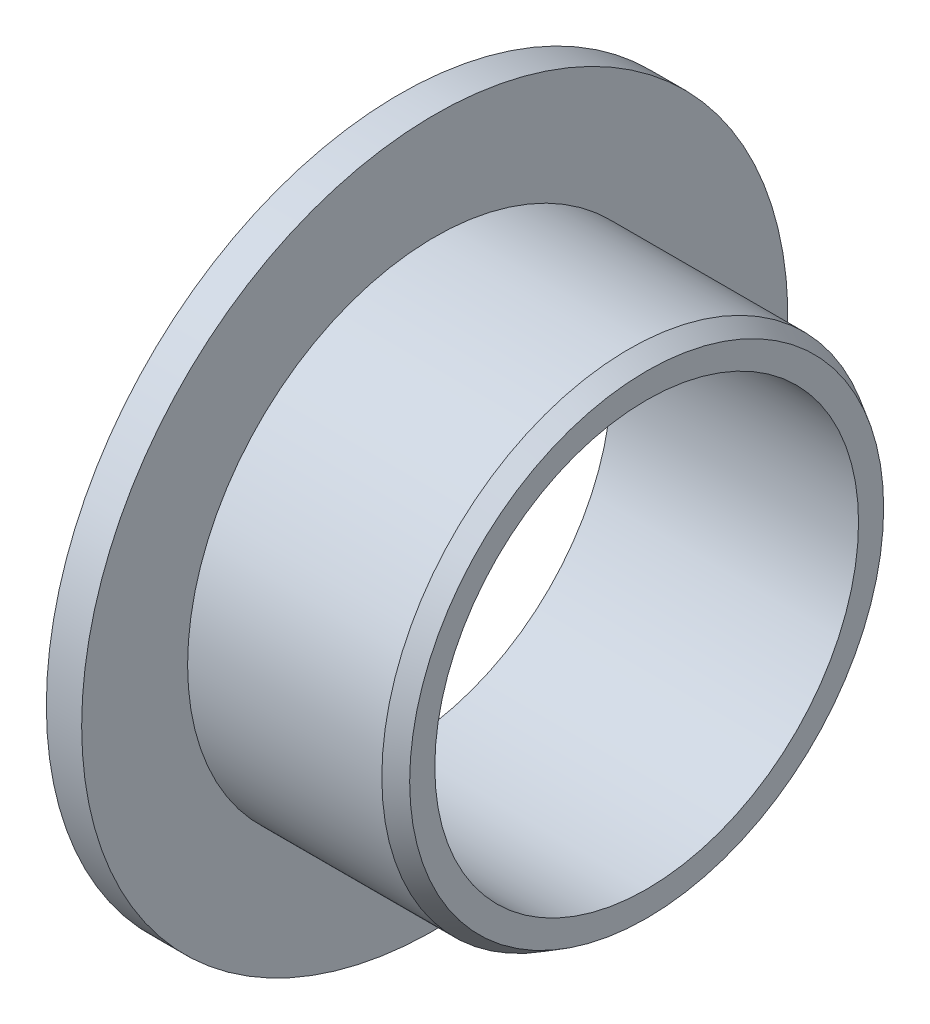
from build123d import *

# Parameters (mm, degrees)
SFAZOWANIE1_SIZE  = 0.5
SFAZOWANIE1_SIZE2 = 0.288675135


with BuildPart() as part:
    # Szkic1 → Obrót1 (revolve)
    with BuildSketch(Plane.XY):
        Polygon((0, 6), (7, 6), (7, 7), (1, 7), (1, 10), (0, 10), align=None)
    revolve(axis=Axis((0, 0, 0), (1, 0, 0)))

    # Sfazowanie1
    sfazowanie1_edges = [part.edges().sort_by_distance(p)[0] for p in [
        (7, -7, 0),
    ]]
    sfazowanie1_side = [part.faces().sort_by_distance(p)[0] for p in [
        (4, -7, 0),
    ]]
    chamfer(sfazowanie1_edges, length=SFAZOWANIE1_SIZE, length2=SFAZOWANIE1_SIZE2, reference=sfazowanie1_side[0])


solid = part.part
